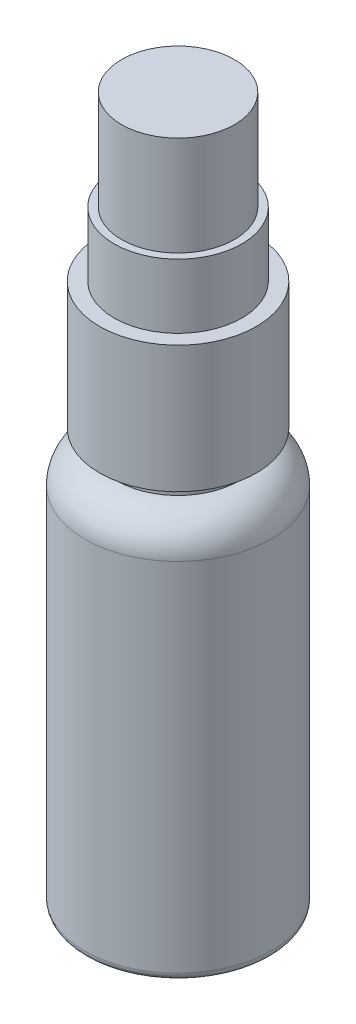
from build123d import *


with BuildPart() as part:
    # Sketch1 → Revolve1 (revolve)
    with BuildSketch(Plane.XY):
        with BuildLine():
            Line((9.75, 0), (10.875, 0))
            ThreePointArc((10.875, 0), (11.582106781, 0.292893219), (11.875, 1))
            Line((11.875, 1), (11.875, 46.5))
            ThreePointArc((11.875, 46.5), (10.593592168, 49.593592168), (7.5, 50.875))
            Line((7.5, 50.875), (7.75, 50.875))
            Line((7.75, 50.875), (7.75, 52.875))
            Line((7.75, 52.875), (10, 52.875))
            Line((10, 52.875), (10, 69.075))
            Line((10, 69.075), (8.15, 69.075))
            Line((8.15, 69.075), (8.15, 77.275))
            Line((8.15, 77.275), (7.2, 77.275))
            Line((7.2, 77.275), (7.2, 89.975))
            Line((7.2, 89.975), (0, 89.975))
            Line((0, 89.975), (0, 65.8))
            Line((0, 65.8), (0, 2.409558552))
            Line((0, 2.409558552), (7.75, 2.409558552))
            ThreePointArc((7.75, 2.409558552), (8.457106781, 2.116665333), (8.75, 1.409558552))
            Line((8.75, 1.409558552), (8.75, 1))
            ThreePointArc((8.75, 1), (9.042893219, 0.292893219), (9.75, 0))
        make_face()
    revolve(axis=Axis((0, 65.8, 0), (0, -1, 0)))


solid = part.part
